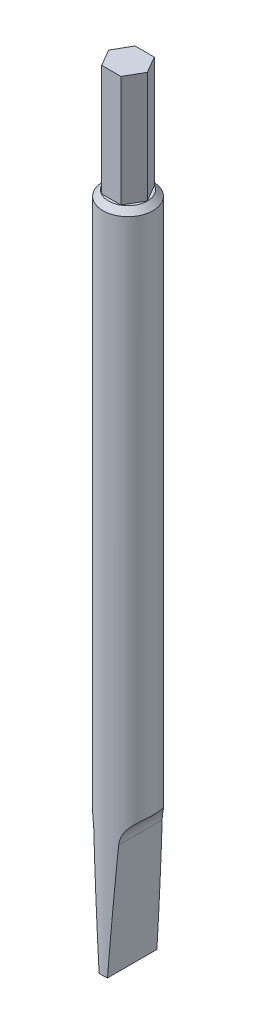
from build123d import *

# Parameters (mm, degrees)
SKETCH1_R               = 4.5
BOSS_EXTRUDE1_DEPTH     = 120
BOSS_EXTRUDE2_DEPTH     = 20
CHAMFER1_SIZE           = 1
CUT_EXTRUDE1_DEPTH      = 5.5
CUT_EXTRUDE1_DEPTH_BACK = 5.5


with BuildPart() as part:
    # Sketch1 → Boss-Extrude1 (new body)
    with BuildSketch(Plane(origin=(0, 0, 0), x_dir=(1, 0, 0), z_dir=(0, 1, 0))):
        Circle(SKETCH1_R)
    extrude(amount=BOSS_EXTRUDE1_DEPTH)

    # Sketch2 → Boss-Extrude2 (add)
    with BuildSketch(Plane(origin=(0, 120, 0), x_dir=(1, 0, 0), z_dir=(0, 1, 0))):
        Polygon((1.732050808, 3), (-1.732050808, 3), (-3.464101615, 0), (-1.732050808, -3), (1.732050808, -3), (3.464101615, 0), align=None)
    extrude(amount=BOSS_EXTRUDE2_DEPTH)

    # Chamfer1
    chamfer1_edges = [part.edges().sort_by_distance(p)[0] for p in [
        (-4.5, 120, 0),
    ]]
    chamfer(chamfer1_edges, length=CHAMFER1_SIZE)

    # Sketch3 → Cut-Extrude1 (cut, two sides)
    with BuildSketch(Plane.XY) as cut_extrude1_sk:
        with BuildLine():
            Line((0.75, 0), (2.229044758, 21.151325457))
            ThreePointArc((2.229044758, 21.151325457), (2.910634909, 23.343484317), (4.5, 25))
            Line((4.5, 25), (4.5, 0))
            Line((4.5, 0), (0.75, 0))
        make_face()
        with BuildLine():
            Line((-4.5, 25), (-4.5, 0))
            Line((-4.5, 0), (-0.75, 0))
            Line((-0.75, 0), (-2.229044758, 21.151325457))
            ThreePointArc((-2.229044758, 21.151325457), (-2.910634909, 23.343484317), (-4.5, 25))
        make_face()
    extrude(amount=CUT_EXTRUDE1_DEPTH, mode=Mode.SUBTRACT)
    extrude(cut_extrude1_sk.sketch, amount=-CUT_EXTRUDE1_DEPTH_BACK, mode=Mode.SUBTRACT)


solid = part.part
